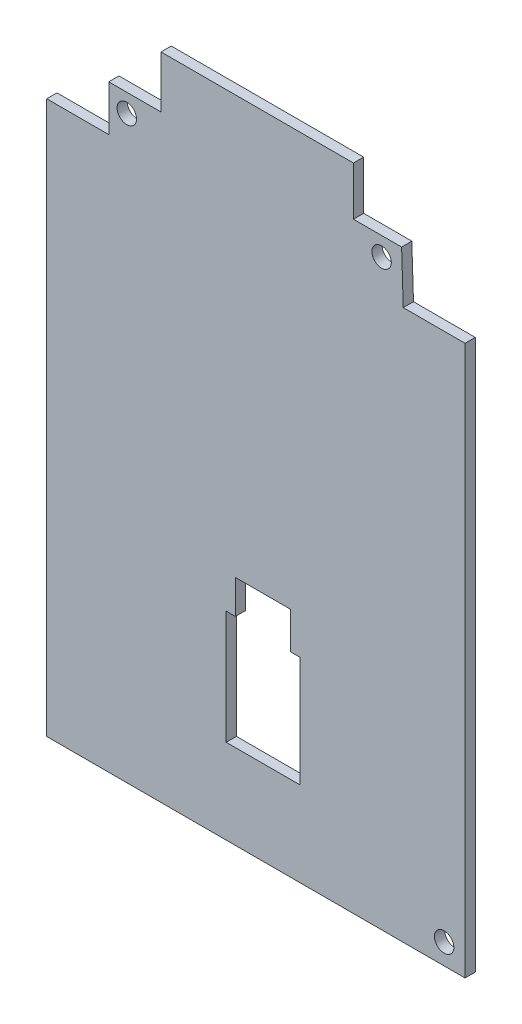
from build123d import *

# Parameters (mm, degrees)
BOSS_EXTRUDE1_DEPTH = 6
SKETCH9_R           = 5.691956205
SKETCH9_R_2         = 5.691972425
SKETCH9_R_3         = 5.691961612
CUT_EXTRUDE1_DEPTH  = 6
SCALE2_SCALE        = 0.3527


with BuildPart() as part:
    # Sketch8 → Boss-Extrude1 (new body)
    with BuildSketch(Plane.XY):
        Polygon((455.046069669, 138.815328461), (455.046069669, 461.140101754), (418.818767583, 461.140101754), (417.854464359, 491.424711157), (389.623159284, 491.424711157), (389.623159284, 519.966114473), (276.778792345, 519.966114473), (276.778792345, 489.453304052), (246.138948372, 489.453304052), (246.138948372, 462.665142262), (209.772989289, 462.665142262), (209.772989289, 138.815328461), align=None)
        Polygon((352.800007218, 274.896015056), (320.400005452, 274.896015056), (320.400005452, 255.096012775), (315.000008762, 255.096012775), (315.000008762, 188.496024764), (358.200003908, 188.496024764), (358.200003908, 253.29600667), (352.800007218, 253.29600667), align=None, mode=Mode.SUBTRACT)
    extrude(amount=BOSS_EXTRUDE1_DEPTH)

    # Sketch9 → Cut-Extrude1 (cut)
    with BuildSketch(Plane(origin=(0, 0, 0), x_dir=(-1, 0, 0), z_dir=(0, 0, -1))):
        with Locations((-442.800031348, 150.987964196)):
            Circle(SKETCH9_R)
        with Locations((-256.719699101, 478.692872416)):
            Circle(SKETCH9_R_2)
        with Locations((-406.119708447, 480.492867708)):
            Circle(SKETCH9_R_3)
    extrude(amount=-CUT_EXTRUDE1_DEPTH, mode=Mode.SUBTRACT)


with BuildPart() as part_1:
    # Scale2: scaled about (332.105882885, 321.548539841, 3)
    add(part.part.scale(SCALE2_SCALE).moved(Location((214.972137991, 208.138369839, 1.9419))))


solid = part_1.part
